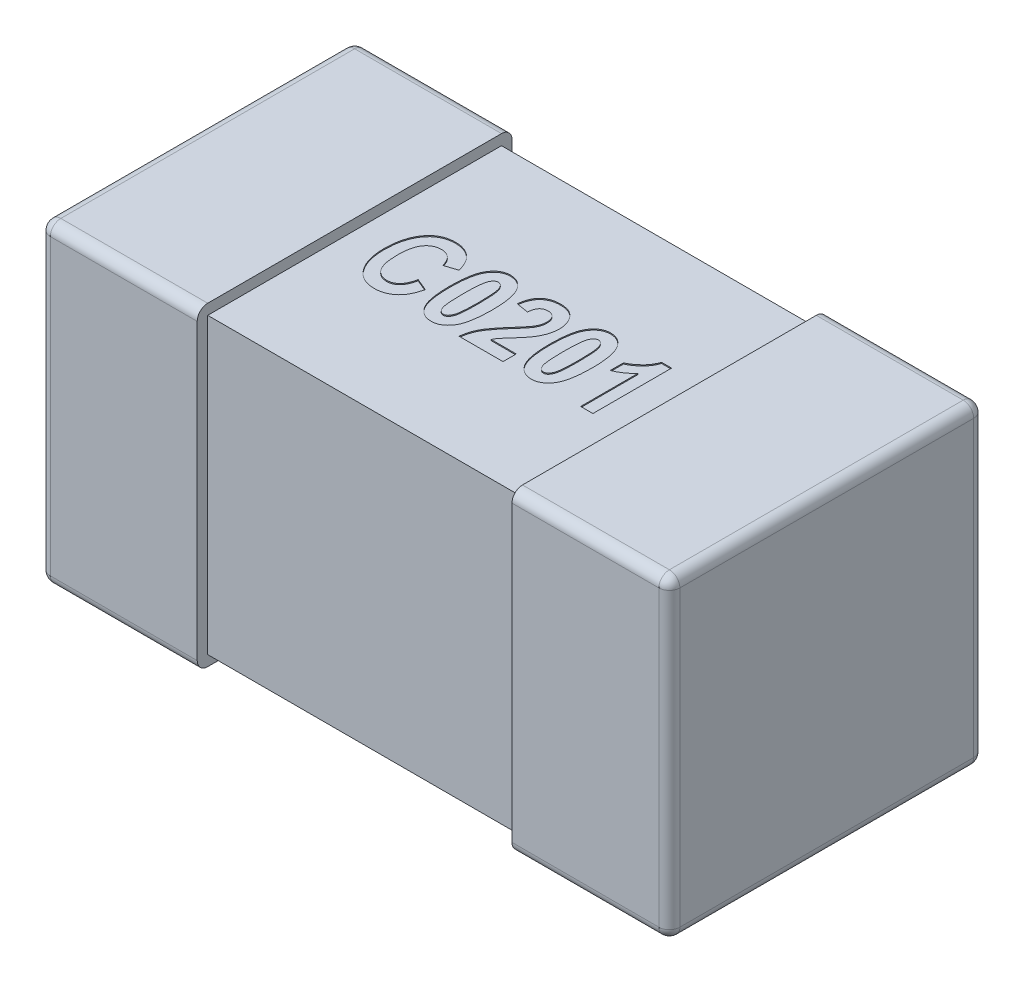
from build123d import *

# Parameters (mm, degrees)
SKETCH1_W            = 0.15
SKETCH1_H            = 0.3
THICKNESS_DEPTH      = 0.3
FILLET1_R            = 0.01
SKETCH2_W            = 0.28
SKETCH2_H            = 0.28
BOSS_EXTRUDE2_DEPTH  = 0.15
FILLET1_OF_MIRROR3_R = 0.01
CUT_EXTRUDE1_DEPTH   = 0.001


with BuildPart() as part:
    # Sketch1 → THICKNESS (new body)
    with BuildSketch(Plane(origin=(0, 0, 0), x_dir=(1, 0, 0), z_dir=(0, 1, 0))):
        with Locations((-0.225, 0)):
            Rectangle(SKETCH1_W, SKETCH1_H)
    thickness = extrude(amount=THICKNESS_DEPTH)

    # Fillet1
    fillet1_edges = [part.edges().sort_by_distance(p)[0] for p in [
        (-0.225, 0.3, -0.15),
        (-0.3, 0.3, 0),
        (-0.225, 0, -0.15),
        (-0.225, 0, 0.15),
        (-0.3, 0, 0),
        (-0.225, 0.3, 0.15),
        (-0.3, 0.15, -0.15),
        (-0.3, 0.15, 0.15),
    ]]
    fillet(fillet1_edges, radius=FILLET1_R)

    # Sketch2 → Boss-Extrude2 (add)
    with BuildSketch(Plane(origin=(0, 0, 0), x_dir=(0, 0, -1), z_dir=(1, 0, 0))):
        with Locations((0, 0.15)):
            Rectangle(SKETCH2_W, SKETCH2_H)
    boss_extrude2 = extrude(amount=-BOSS_EXTRUDE2_DEPTH)

    # Mirror3: THICKNESS, Boss-Extrude2 across plane
    add(thickness.mirror(Plane(origin=(0, 0, 0), x_dir=(0, 0, 1), z_dir=(1, 0, 0))))
    add(boss_extrude2.mirror(Plane(origin=(0, 0, 0), x_dir=(0, 0, 1), z_dir=(1, 0, 0))))

    # Fillet1 of Mirror3
    fillet1_of_mirror3_edges = [part.edges().sort_by_distance(p)[0] for p in [
        (0.225, 0.3, -0.15),
        (0.3, 0.3, 0),
        (0.225, 0, -0.15),
        (0.225, 0, 0.15),
        (0.3, 0, 0),
        (0.225, 0.3, 0.15),
        (0.3, 0.15, -0.15),
        (0.3, 0.15, 0.15),
    ]]
    fillet(fillet1_of_mirror3_edges, radius=FILLET1_OF_MIRROR3_R)

    # Sketch3 → Cut-Extrude1 (cut)
    with BuildSketch(Plane(origin=(0, 0.29, 0), x_dir=(1, 0, 0), z_dir=(0, 1, 0))):
        with BuildLine():
            Line((-0.079220779, -0.010227273), (-0.067532468, -0.015097403))
            add(Edge.make_bspline(
                [(-0.067532468, -0.015097403), (-0.067773864, -0.016079913), (-0.068244238, -0.017994383), (-0.069134121, -0.020730698), (-0.070113335, -0.023269582), (-0.071233611, -0.025596823), (-0.07245654, -0.02773284), (-0.073814966, -0.029656613), (-0.07528333, -0.031377991), (-0.076869985, -0.032892953), (-0.078572358, -0.034196456), (-0.080342649, -0.035358011), (-0.082226574, -0.036310237), (-0.084197751, -0.037114247), (-0.086271679, -0.037711894), (-0.0884326, -0.038161648), (-0.09068979, -0.038419018), (-0.092227454, -0.038455484), (-0.093009334, -0.038474026)],
                knots=[0, 0, 0, 0, 1.282586353, 2.499182829, 3.646034602, 4.730797578, 5.771318175, 6.763713287, 7.712684321, 8.6363956, 9.539720391, 10.428356747, 11.317388874, 12.212151588, 13.124116906, 14.050177375, 15.008543639, 16, 16, 16, 16], degree=3))
            add(Edge.make_bspline(
                [(-0.093009334, -0.038474026), (-0.093990356, -0.03845197), (-0.095912154, -0.038408763), (-0.098716426, -0.03794387), (-0.101384933, -0.037237544), (-0.103912864, -0.036223257), (-0.106303217, -0.034926782), (-0.10853074, -0.033320907), (-0.11064741, -0.031465416), (-0.111878107, -0.03001868), (-0.112505073, -0.029281656)],
                knots=[0, 0, 0, 0, 1.053414494, 2.063614103, 3.046293227, 4.01520277, 4.983805463, 5.961130836, 6.961320097, 8, 8, 8, 8], degree=3))
            add(Edge.make_bspline(
                [(-0.112505073, -0.029281656), (-0.113194234, -0.028371707), (-0.114582613, -0.026538531), (-0.116325646, -0.023515628), (-0.117808129, -0.020268026), (-0.119021468, -0.016792782), (-0.119967202, -0.013086046), (-0.120628393, -0.009146052), (-0.121025458, -0.004974704), (-0.121077354, -0.00211635), (-0.121103896, -0.000654424)],
                knots=[0, 0, 0, 0, 0.898140554, 1.809387162, 2.740718204, 3.705966939, 4.703925369, 5.74945803, 6.848943185, 8, 8, 8, 8], degree=3))
            add(Edge.make_bspline(
                [(-0.121103896, -0.000654424), (-0.121079648, 0.000888846), (-0.121032416, 0.003894878), (-0.120607164, 0.008271374), (-0.119958886, 0.012397368), (-0.11899233, 0.016257524), (-0.117781506, 0.019874008), (-0.116285537, 0.023224268), (-0.114548566, 0.026343343), (-0.113131397, 0.02820616), (-0.112428977, 0.029129464)],
                knots=[0, 0, 0, 0, 1.171098873, 2.281104103, 3.334483992, 4.338438261, 5.297974877, 6.225356982, 7.120398547, 8, 8, 8, 8], degree=3))
            add(Edge.make_bspline(
                [(-0.112428977, 0.029129464), (-0.111791215, 0.029875811), (-0.110534322, 0.031346699), (-0.108385993, 0.033251396), (-0.106078013, 0.034870456), (-0.103611217, 0.036196055), (-0.100974568, 0.037227063), (-0.098180969, 0.037954558), (-0.095219236, 0.038383809), (-0.093193388, 0.038443494), (-0.092157062, 0.038474026)],
                knots=[0, 0, 0, 0, 1.017460211, 2.005195831, 2.96880208, 3.936538458, 4.903086366, 5.898753713, 6.925103759, 8, 8, 8, 8], degree=3))
            add(Edge.make_bspline(
                [(-0.092157062, 0.038474026), (-0.091308969, 0.038453726), (-0.089642082, 0.038413827), (-0.087197894, 0.038094855), (-0.084869205, 0.037533988), (-0.082633282, 0.036798305), (-0.080509742, 0.035813969), (-0.078492446, 0.034619535), (-0.076573459, 0.033218929), (-0.075410331, 0.032130089), (-0.074822443, 0.031579748)],
                knots=[0, 0, 0, 0, 1.062174293, 2.087653736, 3.080296642, 4.058948008, 5.03139012, 6.005719887, 6.992016441, 8, 8, 8, 8], degree=3))
            add(Edge.make_bspline(
                [(-0.074822443, 0.031579748), (-0.07441369, 0.031155591), (-0.073580766, 0.030291278), (-0.072459233, 0.028835396), (-0.071420887, 0.027232024), (-0.070484346, 0.025474321), (-0.069613674, 0.023579464), (-0.068821957, 0.021537742), (-0.068125466, 0.019344509), (-0.067733187, 0.017823645), (-0.067532468, 0.017045455)],
                knots=[0, 0, 0, 0, 0.858002413, 1.748367619, 2.673305357, 3.63929672, 4.648357542, 5.711115493, 6.828831091, 8, 8, 8, 8], degree=3))
            Line((-0.067532468, 0.017045455), (-0.079220779, 0.013149351))
            add(Edge.make_bspline(
                [(-0.079220779, 0.013149351), (-0.079330614, 0.013648193), (-0.079544333, 0.014618856), (-0.079973428, 0.016019656), (-0.080495833, 0.017320721), (-0.081064217, 0.018553284), (-0.081748646, 0.019674713), (-0.08246458, 0.020738592), (-0.08330408, 0.021681147), (-0.084190989, 0.022551906), (-0.085156589, 0.023304387), (-0.086144968, 0.023984888), (-0.087185593, 0.024550674), (-0.088274123, 0.025005709), (-0.089397665, 0.02537397), (-0.090564592, 0.02563294), (-0.091772233, 0.025789763), (-0.092592865, 0.025804307), (-0.093009334, 0.025811688)],
                knots=[0, 0, 0, 0, 1.200071046, 2.335138942, 3.437621639, 4.493482591, 5.51985659, 6.521917265, 7.50210956, 8.480124453, 9.438987346, 10.374745328, 11.297656865, 12.216555725, 13.143999084, 14.072438006, 15.021767148, 16, 16, 16, 16], degree=3))
            add(Edge.make_bspline(
                [(-0.093009334, 0.025811688), (-0.093598741, 0.025794213), (-0.094758755, 0.02575982), (-0.096458274, 0.025486182), (-0.09806625, 0.025002192), (-0.099606891, 0.024366808), (-0.10105431, 0.023520288), (-0.102424618, 0.02249514), (-0.103680971, 0.021260384), (-0.104885052, 0.019871495), (-0.105976154, 0.018262293), (-0.106902573, 0.016402483), (-0.107666702, 0.014298705), (-0.108324908, 0.011966047), (-0.108817367, 0.009389184), (-0.109159119, 0.006572105), (-0.10937241, 0.003518896), (-0.109400862, 0.001400529), (-0.109415584, 0.000304383)],
                knots=[0, 0, 0, 0, 0.827686898, 1.628972485, 2.409099021, 3.181967192, 3.964173723, 4.757978677, 5.579415306, 6.433460257, 7.33665582, 8.302235029, 9.343905073, 10.476376866, 11.703364719, 13.024698166, 14.460435141, 16, 16, 16, 16], degree=3))
            add(Edge.make_bspline(
                [(-0.109415584, 0.000304383), (-0.109398949, -0.00083219), (-0.109366914, -0.003020887), (-0.109180175, -0.006182098), (-0.10882523, -0.009086527), (-0.108370872, -0.011745594), (-0.107749127, -0.014143757), (-0.106989545, -0.016282484), (-0.106114627, -0.018182656), (-0.105070944, -0.019819342), (-0.103914523, -0.021232288), (-0.102685035, -0.022459034), (-0.101358745, -0.023483809), (-0.099971134, -0.024352301), (-0.098484106, -0.02501042), (-0.096915254, -0.02545819), (-0.095273883, -0.025767891), (-0.094147183, -0.025796894), (-0.093572443, -0.025811688)],
                knots=[0, 0, 0, 0, 1.588381619, 3.058741945, 4.422565575, 5.675514383, 6.825848758, 7.879737597, 8.8437938, 9.742560847, 10.584031071, 11.391113559, 12.163968987, 12.921455088, 13.673648094, 14.427376256, 15.197789283, 16, 16, 16, 16], degree=3))
            add(Edge.make_bspline(
                [(-0.093572443, -0.025811688), (-0.09315092, -0.025798633), (-0.092314735, -0.025772736), (-0.091084283, -0.025607831), (-0.089896917, -0.025312983), (-0.088752477, -0.024903915), (-0.087655841, -0.024364203), (-0.086595757, -0.0237248), (-0.085593641, -0.022956231), (-0.08462349, -0.022083558), (-0.083708463, -0.021079831), (-0.082872197, -0.019925827), (-0.082095212, -0.018642171), (-0.081382205, -0.017220903), (-0.080728628, -0.015671158), (-0.080152365, -0.013981042), (-0.0796309, -0.012158994), (-0.079360119, -0.010883582), (-0.079220779, -0.010227273)],
                knots=[0, 0, 0, 0, 0.874040642, 1.73385169, 2.568061146, 3.406503852, 4.248567505, 5.09821747, 5.96915136, 6.862782357, 7.800986125, 8.779254107, 9.812897901, 10.908933612, 12.073249979, 13.297367906, 14.609261928, 16, 16, 16, 16], degree=3))
        make_face()
        with BuildLine():
            add(Edge.make_bspline(
                [(-0.03882914, 0.0375), (-0.038101875, 0.037473269), (-0.036666823, 0.037420522), (-0.034573044, 0.037015009), (-0.032579773, 0.036356198), (-0.030700781, 0.035421595), (-0.028934921, 0.034217838), (-0.027277756, 0.032752269), (-0.025727988, 0.031025516), (-0.02427565, 0.029022082), (-0.02297053, 0.026678965), (-0.02185587, 0.023953999), (-0.020919739, 0.020837776), (-0.020156929, 0.017330674), (-0.019551814, 0.013427709), (-0.019142023, 0.009128524), (-0.018881119, 0.004437074), (-0.018848255, 0.001177325), (-0.018831169, -0.000517451)],
                knots=[0, 0, 0, 0, 0.727503026, 1.435521033, 2.125933754, 2.823035237, 3.52857293, 4.258887692, 5.031802202, 5.846339271, 6.730577678, 7.709342118, 8.787052798, 9.983216815, 11.298799232, 12.737663191, 14.303878888, 16, 16, 16, 16], degree=3))
            add(Edge.make_bspline(
                [(-0.018831169, -0.000517451), (-0.018848293, -0.002207147), (-0.018881225, -0.005456744), (-0.019141546, -0.010133101), (-0.019553639, -0.014421726), (-0.020153838, -0.018315625), (-0.020925803, -0.021820188), (-0.021848737, -0.024935748), (-0.022975055, -0.027656068), (-0.024274242, -0.029997133), (-0.025729275, -0.031993926), (-0.027262168, -0.033731054), (-0.028920165, -0.035191801), (-0.030682652, -0.036391035), (-0.032552457, -0.037334406), (-0.034533703, -0.037983718), (-0.036615401, -0.038397511), (-0.038040824, -0.038448172), (-0.038768263, -0.038474026)],
                knots=[0, 0, 0, 0, 1.695059366, 3.259911835, 4.697127445, 6.015833273, 7.209868934, 8.295006778, 9.271397414, 10.15773515, 10.974206064, 11.745554658, 12.477603308, 13.184816065, 13.879016739, 14.571068615, 15.270769761, 16, 16, 16, 16], degree=3))
            add(Edge.make_bspline(
                [(-0.038768263, -0.038474026), (-0.039495218, -0.038445587), (-0.04092873, -0.038389508), (-0.043026063, -0.038008903), (-0.045017891, -0.037344865), (-0.046892178, -0.036409434), (-0.048662607, -0.035223884), (-0.050318925, -0.033772127), (-0.051870784, -0.032062031), (-0.053050567, -0.030434566), (-0.053937682, -0.028995739), (-0.054556529, -0.02779227), (-0.055133321, -0.026488869), (-0.055688509, -0.025092901), (-0.056164245, -0.023577055), (-0.056623189, -0.021970077), (-0.057035173, -0.020259079), (-0.057390657, -0.018449362), (-0.057738276, -0.016544747), (-0.057996666, -0.014531281), (-0.058252337, -0.012422719), (-0.05842199, -0.010203019), (-0.058580832, -0.00789012), (-0.058678688, -0.005469282), (-0.058766564, -0.002953143), (-0.058766345, -0.001237912), (-0.058766234, -0.00036526)],
                knots=[0, 0, 0, 0, 1.088325032, 2.146111092, 3.178950023, 4.221795161, 5.273015815, 6.360545385, 7.511177693, 8.723556364, 9.364476831, 10.040531105, 10.747741516, 11.498134997, 12.288409729, 13.125171687, 14.000253567, 14.922333743, 15.886381247, 16.898284178, 17.961049106, 19.066181515, 20.23079341, 21.432081124, 22.693528529, 24, 24, 24, 24], degree=3))
            add(Edge.make_bspline(
                [(-0.058766234, -0.00036526), (-0.05874916, 0.001319372), (-0.058716327, 0.004558848), (-0.058455438, 0.009219895), (-0.05804585, 0.013488708), (-0.057439576, 0.01736624), (-0.056674802, 0.02085725), (-0.055745498, 0.02396583), (-0.054622649, 0.026682131), (-0.053323089, 0.029023086), (-0.051868144, 0.031019905), (-0.05033523, 0.032757027), (-0.048677239, 0.034217776), (-0.046914751, 0.035417009), (-0.045044946, 0.03636038), (-0.043063699, 0.037009692), (-0.040982001, 0.037423485), (-0.039556579, 0.037474146), (-0.03882914, 0.0375)],
                knots=[0, 0, 0, 0, 1.69316225, 3.255878705, 4.690734649, 6.001855936, 7.198146525, 8.280455951, 9.258690493, 10.146702072, 10.964714887, 11.737520167, 12.470951286, 13.179499609, 13.875011277, 14.568370088, 15.269392615, 16, 16, 16, 16], degree=3))
        make_face()
        with BuildLine():
            add(Edge.make_bspline(
                [(-0.038798701, 0.025811688), (-0.039068997, 0.025796141), (-0.039607817, 0.025765149), (-0.040391402, 0.025542856), (-0.041136998, 0.02518918), (-0.041830465, 0.024674405), (-0.04246699, 0.024005364), (-0.043078234, 0.023211876), (-0.043640256, 0.022271011), (-0.044179889, 0.021159671), (-0.044638463, 0.019764129), (-0.0450423, 0.0180237), (-0.045359986, 0.015890284), (-0.045625811, 0.013366128), (-0.045856742, 0.010453653), (-0.045996627, 0.007144002), (-0.046089237, 0.003445143), (-0.046098848, 0.000847268), (-0.046103896, -0.000517451)],
                knots=[0, 0, 0, 0, 0.441180509, 0.879471584, 1.320574249, 1.783035872, 2.281174677, 2.824866155, 3.41612178, 4.06851155, 4.839013556, 5.809909241, 6.984378085, 8.359905701, 9.955928005, 11.756194428, 13.770637572, 16, 16, 16, 16], degree=3))
            add(Edge.make_bspline(
                [(-0.046103896, -0.000517451), (-0.046098939, -0.001882175), (-0.04608952, -0.004474986), (-0.045996032, -0.008168725), (-0.045857895, -0.011468366), (-0.045623452, -0.014380503), (-0.045362773, -0.016900165), (-0.045040833, -0.019033114), (-0.044637591, -0.02076815), (-0.044184011, -0.02216103), (-0.043636401, -0.023263609), (-0.043077681, -0.024200361), (-0.042472303, -0.024994857), (-0.041825136, -0.025648207), (-0.041137595, -0.026163797), (-0.040391247, -0.026516729), (-0.039607856, -0.026739214), (-0.03906901, -0.02677018), (-0.038798701, -0.026785714)],
                knots=[0, 0, 0, 0, 2.233529834, 4.243438314, 6.047070022, 7.637798311, 9.024151416, 10.192614236, 11.165324842, 11.937267167, 12.583397913, 13.175758788, 13.720466603, 14.213631053, 14.676957167, 15.118884396, 15.557994781, 16, 16, 16, 16], degree=3))
            add(Edge.make_bspline(
                [(-0.038798701, -0.026785714), (-0.038523329, -0.026770503), (-0.03797941, -0.026740457), (-0.037190235, -0.026517586), (-0.036443572, -0.026158629), (-0.035736634, -0.025654659), (-0.035106538, -0.024979156), (-0.034481306, -0.024204611), (-0.033946124, -0.02325442), (-0.033401418, -0.02214988), (-0.032939898, -0.020755111), (-0.032565322, -0.019008948), (-0.032214456, -0.01688179), (-0.031955494, -0.014360607), (-0.03174534, -0.0114524), (-0.031599525, -0.00815362), (-0.031508553, -0.004464805), (-0.031498689, -0.00187709), (-0.031493506, -0.000517451)],
                knots=[0, 0, 0, 0, 0.450046871, 0.888937661, 1.330643888, 1.800456046, 2.299276457, 2.837157917, 3.424961576, 4.078244013, 4.849800298, 5.820145492, 6.997538181, 8.374947934, 9.964252522, 11.766982255, 13.775885602, 16, 16, 16, 16], degree=3))
            add(Edge.make_bspline(
                [(-0.031493506, -0.000517451), (-0.03149873, 0.000847258), (-0.031508674, 0.003445113), (-0.031599049, 0.007144102), (-0.031746101, 0.010452955), (-0.031954679, 0.013366344), (-0.032214506, 0.015892552), (-0.032565352, 0.018019671), (-0.032939782, 0.019765957), (-0.033401741, 0.021160385), (-0.033945155, 0.022265924), (-0.03448641, 0.023216446), (-0.035101435, 0.024004025), (-0.035737205, 0.02468019), (-0.036443433, 0.025184712), (-0.037190271, 0.025543532), (-0.037979401, 0.025766438), (-0.038523326, 0.025796479), (-0.038798701, 0.025811688)],
                knots=[0, 0, 0, 0, 2.228036839, 4.241282185, 6.040478161, 7.634927745, 9.009637465, 10.184722199, 11.153165298, 11.923209159, 12.575211015, 13.161862447, 13.705230643, 14.203073253, 14.671964473, 15.112804857, 15.550835322, 16, 16, 16, 16], degree=3))
        make_face(mode=Mode.SUBTRACT)
        with BuildLine():
            Line((0.028896104, -0.024837662), (0.028896104, -0.0375))
            Line((0.028896104, -0.0375), (-0.012987013, -0.0375))
            add(Edge.make_bspline(
                [(-0.012987013, -0.0375), (-0.012839649, -0.036252891), (-0.012545322, -0.033762061), (-0.011654085, -0.030106274), (-0.01045271, -0.026534895), (-0.009137201, -0.023626814), (-0.007831722, -0.02127876), (-0.006663883, -0.019362938), (-0.005273114, -0.017324308), (-0.003661075, -0.015165631), (-0.001873616, -0.012854919), (0.000128796, -0.010416408), (0.002335732, -0.007847949), (0.003893068, -0.006105279), (0.004697646, -0.005204951)],
                knots=[0, 0, 0, 0, 1.20268352, 2.402099407, 3.598367202, 4.810420478, 5.454599206, 6.172593709, 6.960183653, 7.818888272, 8.754527026, 9.759992126, 10.842728215, 12, 12, 12, 12], degree=3))
            add(Edge.make_bspline(
                [(0.004697646, -0.005204951), (0.005328488, -0.004501367), (0.006535343, -0.003155349), (0.008232891, -0.001206187), (0.00975983, 0.000546584), (0.011067499, 0.002139149), (0.012201976, 0.003538208), (0.013142178, 0.004765088), (0.013899383, 0.005809155), (0.014304109, 0.006466042), (0.014483563, 0.006757305)],
                knots=[0, 0, 0, 0, 1.465870871, 2.804341841, 4.009590698, 5.071600616, 6.000740577, 6.80347298, 7.469461756, 8, 8, 8, 8], degree=3))
            add(Edge.make_bspline(
                [(0.014483563, 0.006757305), (0.014900051, 0.007503388), (0.015713043, 0.008959758), (0.016559647, 0.011267635), (0.017113021, 0.013579673), (0.017176435, 0.01513496), (0.017207792, 0.015904018)],
                knots=[0, 0, 0, 0, 1.060288104, 2.069705834, 3.04550853, 4, 4, 4, 4], degree=3))
            add(Edge.make_bspline(
                [(0.017207792, 0.015904018), (0.017180859, 0.016672424), (0.017129872, 0.018127067), (0.016693515, 0.02015945), (0.015964033, 0.021907271), (0.014909639, 0.023326356), (0.013626008, 0.024440283), (0.012145434, 0.025253143), (0.010469786, 0.025734671), (0.009291928, 0.0257855), (0.008685065, 0.025811688)],
                knots=[0, 0, 0, 0, 1.245810787, 2.358399634, 3.353971925, 4.295778042, 5.200327805, 6.09189762, 7.016895116, 8, 8, 8, 8], degree=3))
            add(Edge.make_bspline(
                [(0.008685065, 0.025811688), (0.008026985, 0.025782931), (0.006765661, 0.025727814), (0.004991657, 0.025214664), (0.003451912, 0.024368769), (0.002190138, 0.023141075), (0.001154568, 0.021607278), (0.000406908, 0.019721896), (-0.000105704, 0.017520747), (-0.000248775, 0.015937389), (-0.000324675, 0.015097403)],
                knots=[0, 0, 0, 0, 0.999920937, 1.916523715, 2.784458762, 3.647604167, 4.570853193, 5.582015381, 6.717234977, 8, 8, 8, 8], degree=3))
            Line((-0.000324675, 0.015097403), (-0.012012987, 0.017045455))
            add(Edge.make_bspline(
                [(-0.012012987, 0.017045455), (-0.011915113, 0.01789987), (-0.01172525, 0.019557334), (-0.011222502, 0.021938052), (-0.010627104, 0.024150947), (-0.009881592, 0.026184566), (-0.008997506, 0.028041563), (-0.007971852, 0.029719891), (-0.006834201, 0.03124779), (-0.005527139, 0.032573637), (-0.004102823, 0.033733579), (-0.002570864, 0.034748838), (-0.000919986, 0.035597785), (0.000835413, 0.036305713), (0.002711221, 0.036829829), (0.004688354, 0.037231065), (0.006782471, 0.037457373), (0.00821275, 0.037485582), (0.008943791, 0.0375)],
                knots=[0, 0, 0, 0, 1.257113927, 2.438652199, 3.554660598, 4.606291011, 5.601856267, 6.557471959, 7.478981492, 8.381416587, 9.2725261, 10.161501808, 11.064119884, 11.98308707, 12.924775989, 13.908409216, 14.930951759, 16, 16, 16, 16], degree=3))
            add(Edge.make_bspline(
                [(0.008943791, 0.0375), (0.009746619, 0.037487071), (0.011302721, 0.037462011), (0.013556917, 0.037136806), (0.015667492, 0.036673457), (0.017613681, 0.035952731), (0.019429508, 0.035085768), (0.021062369, 0.033963425), (0.02257924, 0.032691383), (0.023879755, 0.03118123), (0.025063607, 0.02958499), (0.026080078, 0.027902644), (0.026960179, 0.02617885), (0.027661496, 0.024382782), (0.028207484, 0.022528388), (0.028600958, 0.02061962), (0.028858689, 0.018655582), (0.028883503, 0.017325298), (0.028896104, 0.016649756)],
                knots=[0, 0, 0, 0, 1.185802577, 2.298411505, 3.360827086, 4.373838454, 5.359924385, 6.327149754, 7.295159843, 8.277960573, 9.264958702, 10.230903902, 11.180079425, 12.122922977, 13.076886226, 14.034409875, 15.001838751, 16, 16, 16, 16], degree=3))
            add(Edge.make_bspline(
                [(0.028896104, 0.016649756), (0.028883315, 0.015882989), (0.028857926, 0.014360723), (0.028597178, 0.012093877), (0.028212064, 0.009858622), (0.027640785, 0.00765195), (0.02690206, 0.005462637), (0.026002512, 0.003271728), (0.024936631, 0.001072033), (0.023887036, -0.000750546), (0.02294658, -0.002264715), (0.022109132, -0.003475003), (0.021154735, -0.004756068), (0.020110147, -0.006129465), (0.018934408, -0.007568759), (0.017656192, -0.009091077), (0.016271028, -0.010689265), (0.015301906, -0.011770883), (0.014803166, -0.012327516)],
                knots=[0, 0, 0, 0, 1.112568374, 2.208785751, 3.308090549, 4.402946702, 5.513734595, 6.659701235, 7.83876403, 9.059051271, 9.71083511, 10.425746939, 11.194567613, 12.029688168, 12.930202216, 13.891926091, 14.915120021, 16, 16, 16, 16], degree=3))
            add(Edge.make_bspline(
                [(0.014803166, -0.012327516), (0.014341347, -0.01283973), (0.013460881, -0.013816275), (0.012205038, -0.015214678), (0.011105613, -0.016497532), (0.010109169, -0.01761815), (0.009259251, -0.01860943), (0.00853419, -0.019459053), (0.007966262, -0.020192035), (0.007106052, -0.021262925), (0.006072974, -0.022770312), (0.005339682, -0.024166023), (0.00498681, -0.024837662)],
                knots=[0, 0, 0, 0, 1.297038255, 2.472825099, 3.534584971, 4.474279189, 5.292832013, 5.990344774, 6.574432518, 7.036342243, 8.573839243, 10, 10, 10, 10], degree=3))
            Line((0.00498681, -0.024837662), (0.028896104, -0.024837662))
        make_face()
        with BuildLine():
            add(Edge.make_bspline(
                [(0.056625406, 0.0375), (0.057352671, 0.037473269), (0.058787722, 0.037420522), (0.060881502, 0.037015009), (0.062874773, 0.036356198), (0.064753764, 0.035421595), (0.066519624, 0.034217838), (0.068176789, 0.032752269), (0.069726557, 0.031025516), (0.071178896, 0.029022082), (0.072484015, 0.026678965), (0.073598676, 0.023953999), (0.074534806, 0.020837776), (0.075297617, 0.017330674), (0.075902731, 0.013427709), (0.076312523, 0.009128524), (0.076573426, 0.004437074), (0.07660629, 0.001177325), (0.076623377, -0.000517451)],
                knots=[0, 0, 0, 0, 0.727503026, 1.435521033, 2.125933754, 2.823035237, 3.52857293, 4.258887692, 5.031802202, 5.846339271, 6.730577678, 7.709342118, 8.787052798, 9.983216815, 11.298799232, 12.737663191, 14.303878888, 16, 16, 16, 16], degree=3))
            add(Edge.make_bspline(
                [(0.076623377, -0.000517451), (0.076606253, -0.002207147), (0.07657332, -0.005456744), (0.076313, -0.010133101), (0.075900907, -0.014421726), (0.075300708, -0.018315625), (0.074528742, -0.021820188), (0.073605809, -0.024935748), (0.07247949, -0.027656068), (0.071180303, -0.029997133), (0.06972527, -0.031993926), (0.068192377, -0.033731054), (0.066534381, -0.035191801), (0.064771894, -0.036391035), (0.062902089, -0.037334406), (0.060920842, -0.037983718), (0.058839144, -0.038397511), (0.057413722, -0.038448172), (0.056686282, -0.038474026)],
                knots=[0, 0, 0, 0, 1.695059366, 3.259911835, 4.697127445, 6.015833273, 7.209868934, 8.295006778, 9.271397414, 10.15773515, 10.974206064, 11.745554658, 12.477603308, 13.184816065, 13.879016739, 14.571068615, 15.270769761, 16, 16, 16, 16], degree=3))
            add(Edge.make_bspline(
                [(0.056686282, -0.038474026), (0.055959327, -0.038445587), (0.054525816, -0.038389508), (0.052428482, -0.038008903), (0.050436654, -0.037344865), (0.048562367, -0.036409434), (0.046791939, -0.035223884), (0.04513562, -0.033772127), (0.043583761, -0.032062031), (0.042403978, -0.030434566), (0.041516864, -0.028995739), (0.040898016, -0.02779227), (0.040321224, -0.026488869), (0.039766036, -0.025092901), (0.0392903, -0.023577055), (0.038831357, -0.021970077), (0.038419372, -0.020259079), (0.038063889, -0.018449362), (0.03771627, -0.016544747), (0.03745788, -0.014531281), (0.037202208, -0.012422719), (0.037032555, -0.010203019), (0.036873714, -0.00789012), (0.036775857, -0.005469282), (0.036687981, -0.002953143), (0.0366882, -0.001237912), (0.036688312, -0.00036526)],
                knots=[0, 0, 0, 0, 1.088325032, 2.146111092, 3.178950023, 4.221795161, 5.273015815, 6.360545385, 7.511177693, 8.723556364, 9.364476831, 10.040531105, 10.747741516, 11.498134997, 12.288409729, 13.125171687, 14.000253567, 14.922333743, 15.886381247, 16.898284178, 17.961049106, 19.066181515, 20.23079341, 21.432081124, 22.693528529, 24, 24, 24, 24], degree=3))
            add(Edge.make_bspline(
                [(0.036688312, -0.00036526), (0.036705386, 0.001319372), (0.036738219, 0.004558848), (0.036999107, 0.009219895), (0.037408695, 0.013488708), (0.03801497, 0.01736624), (0.038779743, 0.02085725), (0.039709047, 0.02396583), (0.040831896, 0.026682131), (0.042131456, 0.029023086), (0.043586401, 0.031019905), (0.045119315, 0.032757027), (0.046777307, 0.034217776), (0.048539795, 0.035417009), (0.0504096, 0.03636038), (0.052390846, 0.037009692), (0.054472544, 0.037423485), (0.055897966, 0.037474146), (0.056625406, 0.0375)],
                knots=[0, 0, 0, 0, 1.69316225, 3.255878705, 4.690734649, 6.001855936, 7.198146525, 8.280455951, 9.258690493, 10.146702072, 10.964714887, 11.737520167, 12.470951286, 13.179499609, 13.875011277, 14.568370088, 15.269392615, 16, 16, 16, 16], degree=3))
        make_face()
        with BuildLine():
            add(Edge.make_bspline(
                [(0.056655844, 0.025811688), (0.056385549, 0.025796141), (0.055846728, 0.025765149), (0.055063144, 0.025542856), (0.054317547, 0.02518918), (0.05362408, 0.024674405), (0.052987555, 0.024005364), (0.052376311, 0.023211876), (0.05181429, 0.022271011), (0.051274656, 0.021159671), (0.050816083, 0.019764129), (0.050412245, 0.0180237), (0.05009456, 0.015890284), (0.049828734, 0.013366128), (0.049597803, 0.010453653), (0.049457919, 0.007144002), (0.049365308, 0.003445143), (0.049355698, 0.000847268), (0.049350649, -0.000517451)],
                knots=[0, 0, 0, 0, 0.441180509, 0.879471584, 1.320574249, 1.783035872, 2.281174677, 2.824866155, 3.41612178, 4.06851155, 4.839013556, 5.809909241, 6.984378085, 8.359905701, 9.955928005, 11.756194428, 13.770637572, 16, 16, 16, 16], degree=3))
            add(Edge.make_bspline(
                [(0.049350649, -0.000517451), (0.049355607, -0.001882175), (0.049365026, -0.004474986), (0.049458514, -0.008168725), (0.049596651, -0.011468366), (0.049831094, -0.014380503), (0.050091772, -0.016900165), (0.050413713, -0.019033114), (0.050816954, -0.02076815), (0.051270534, -0.02216103), (0.051818144, -0.023263609), (0.052376864, -0.024200361), (0.052982243, -0.024994857), (0.053629409, -0.025648207), (0.05431695, -0.026163797), (0.055063299, -0.026516729), (0.055846689, -0.026739214), (0.056385536, -0.02677018), (0.056655844, -0.026785714)],
                knots=[0, 0, 0, 0, 2.233529834, 4.243438314, 6.047070022, 7.637798311, 9.024151416, 10.192614236, 11.165324842, 11.937267167, 12.583397913, 13.175758788, 13.720466603, 14.213631053, 14.676957167, 15.118884396, 15.557994781, 16, 16, 16, 16], degree=3))
            add(Edge.make_bspline(
                [(0.056655844, -0.026785714), (0.056931217, -0.026770503), (0.057475135, -0.026740457), (0.05826431, -0.026517586), (0.059010973, -0.026158629), (0.059717911, -0.025654659), (0.060348008, -0.024979156), (0.060973239, -0.024204611), (0.061508422, -0.02325442), (0.062053128, -0.02214988), (0.062514647, -0.020755111), (0.062889223, -0.019008948), (0.063240089, -0.01688179), (0.063499051, -0.014360607), (0.063709205, -0.0114524), (0.06385502, -0.00815362), (0.063945992, -0.004464805), (0.063955856, -0.00187709), (0.063961039, -0.000517451)],
                knots=[0, 0, 0, 0, 0.450046871, 0.888937661, 1.330643888, 1.800456046, 2.299276457, 2.837157917, 3.424961576, 4.078244013, 4.849800298, 5.820145492, 6.997538181, 8.374947934, 9.964252522, 11.766982255, 13.775885602, 16, 16, 16, 16], degree=3))
            add(Edge.make_bspline(
                [(0.063961039, -0.000517451), (0.063955815, 0.000847258), (0.063945872, 0.003445113), (0.063855496, 0.007144102), (0.063708445, 0.010452955), (0.063499867, 0.013366344), (0.063240039, 0.015892552), (0.062889194, 0.018019671), (0.062514763, 0.019765957), (0.062052805, 0.021160385), (0.06150939, 0.022265924), (0.060968135, 0.023216446), (0.060353111, 0.024004025), (0.05971734, 0.02468019), (0.059011112, 0.025184712), (0.058264275, 0.025543532), (0.057475145, 0.025766438), (0.05693122, 0.025796479), (0.056655844, 0.025811688)],
                knots=[0, 0, 0, 0, 2.228036839, 4.241282185, 6.040478161, 7.634927745, 9.009637465, 10.184722199, 11.153165298, 11.923209159, 12.575211015, 13.161862447, 13.705230643, 14.203073253, 14.671964473, 15.112804857, 15.550835322, 16, 16, 16, 16], degree=3))
        make_face(mode=Mode.SUBTRACT)
        with BuildLine():
            Line((0.11461039, -0.0375), (0.102922078, -0.0375))
            Line((0.102922078, -0.0375), (0.102922078, 0.017045455))
            add(Edge.make_bspline(
                [(0.102922078, 0.017045455), (0.102355197, 0.016450602), (0.10123094, 0.015270871), (0.09944233, 0.013623922), (0.097591861, 0.012105521), (0.095667321, 0.010708783), (0.093690733, 0.009420452), (0.091637091, 0.008257563), (0.089523809, 0.007217689), (0.088066904, 0.006626889), (0.087337662, 0.006331169)],
                knots=[0, 0, 0, 0, 1.033480345, 2.049633457, 3.05634389, 4.043072978, 5.039658923, 6.022790494, 7.010324124, 8, 8, 8, 8], degree=3))
            Line((0.087337662, 0.006331169), (0.087337662, 0.018993506))
            add(Edge.make_bspline(
                [(0.087337662, 0.018993506), (0.088178223, 0.019367089), (0.089928222, 0.020144866), (0.092488381, 0.021706482), (0.095074037, 0.023662076), (0.097219495, 0.025539292), (0.098892873, 0.027209454), (0.100085215, 0.028524913), (0.101152668, 0.029914347), (0.102141924, 0.031328158), (0.103015373, 0.032806778), (0.103786507, 0.034321821), (0.104470769, 0.03588317), (0.104827693, 0.036959152), (0.105007102, 0.0375)],
                knots=[0, 0, 0, 0, 1.256071058, 2.615068939, 4.086222451, 5.682781329, 6.506361962, 7.316438188, 8.106904776, 8.89922375, 9.673254088, 10.451495518, 11.221635059, 12, 12, 12, 12], degree=3))
            Line((0.105007102, 0.0375), (0.11461039, 0.0375))
            Line((0.11461039, 0.0375), (0.11461039, -0.0375))
        make_face()
    extrude(amount=-CUT_EXTRUDE1_DEPTH, mode=Mode.SUBTRACT)


solid = part.part
